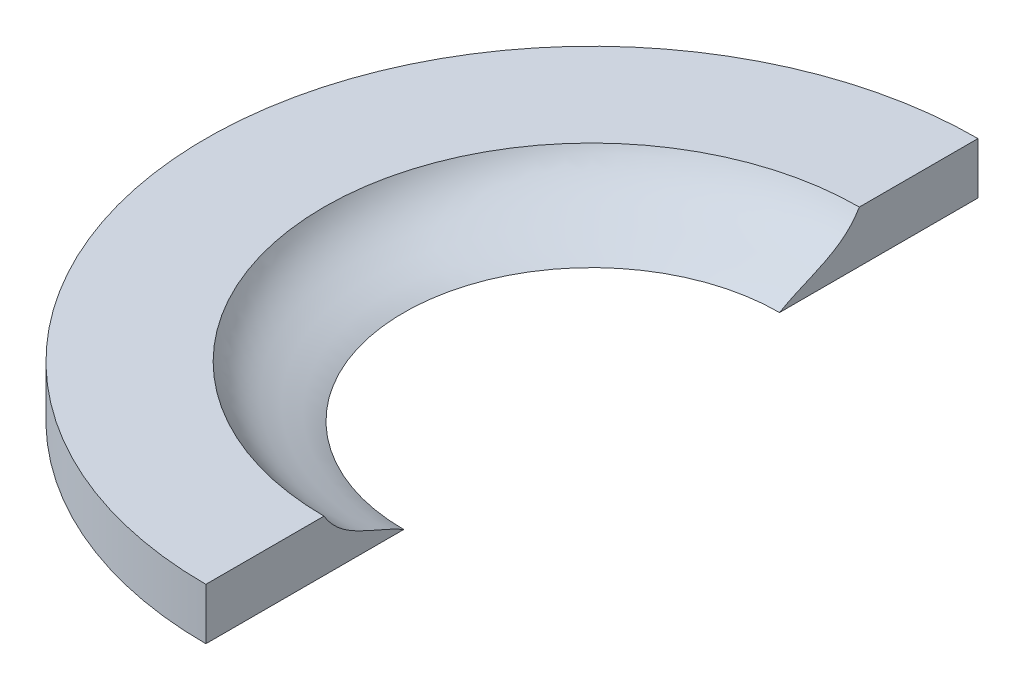
from build123d import *

# Parameters (mm, degrees)
SKETCH1_W           = 127.635
SKETCH1_H           = 127.635
BOSS_EXTRUDE1_DEPTH = 12.7
SKETCH12_R          = 95.4151
BOSS_EXTRUDE2_DEPTH = 12.7
SKETCH5_R           = 46.355
CUT_EXTRUDE1_DEPTH  = 9.525
SKETCH30_R          = 85.09
SKETCH30_R_2        = 79.375
BOSS_EXTRUDE3_DEPTH = 12.7
SKETCH32_R          = 1.35255
CUT_EXTRUDE4_DEPTH  = 15.24
CIRPATTERN2_COUNT   = 12
SKETCH36_R          = 115.31206939
SKETCH36_R_2        = 76.2
CUT_EXTRUDE5_DEPTH  = 35.9250001
SKETCH38_R          = 95.25
SKETCH38_R_2        = 76.2
BOSS_EXTRUDE4_DEPTH = 12.7
SKETCH37_W          = 208.61583397
SKETCH37_H          = 123.882270127
CUT_EXTRUDE6_DEPTH  = 96.25


with BuildPart() as part:
    # Sketch1 → Boss-Extrude1 (new body)
    with BuildSketch(Plane(origin=(0, 0, 0), x_dir=(1, 0, 0), z_dir=(0, 1, 0))):
        with Locations((63.8175, 63.8175)):
            Rectangle(SKETCH1_W, SKETCH1_H)
    extrude(amount=BOSS_EXTRUDE1_DEPTH)

    # Sketch12 → Boss-Extrude2 (add)
    with BuildSketch(Plane.XZ):
        with Locations((63.8175, -63.8175)):
            Circle(SKETCH12_R)
    extrude(amount=-BOSS_EXTRUDE2_DEPTH)

    # Sketch5 → Cut-Extrude1 (cut)
    with BuildSketch(Plane(origin=(0, 12.7, 0), x_dir=(1, 0, 0), z_dir=(0, 1, 0))):
        with Locations((63.8175, 63.8175)):
            Circle(SKETCH5_R)
    extrude(amount=-CUT_EXTRUDE1_DEPTH, mode=Mode.SUBTRACT)

    # Sketch30 → Boss-Extrude3 (add)
    with BuildSketch(Plane.XZ):
        with Locations((63.8175, -63.8175)):
            Circle(SKETCH30_R)
        with Locations((63.8175, -63.8175)):
            Circle(SKETCH30_R_2, mode=Mode.SUBTRACT)
    boss_extrude3 = extrude(amount=BOSS_EXTRUDE3_DEPTH)

    # Mirror1: Boss-Extrude3 across plane
    add(boss_extrude3.mirror(Plane.ZX.offset(4.7625)))

    # Sketch32 → Cut-Extrude4 (cut)
    with BuildSketch(Plane(origin=(0, 0, -148.9075), x_dir=(-1, 0, 0), z_dir=(0, 0, -1))):
        with Locations((-63.8175, -6.35)):
            Circle(SKETCH32_R)
        with Locations((-63.8175, 19.05)):
            Circle(SKETCH32_R)
    cut_extrude4 = extrude(amount=-CUT_EXTRUDE4_DEPTH, mode=Mode.SUBTRACT)

    # CirPattern2: Cut-Extrude4 ×12 about axis
    cirpattern2_axis = Axis((63.8175, -12.7, -63.8175), (0, 1, 0))
    for i in range(1, CIRPATTERN2_COUNT):
        add(cut_extrude4.rotate(cirpattern2_axis, i * 360 / CIRPATTERN2_COUNT), mode=Mode.SUBTRACT)

    # Sketch35 → Cut-Revolve1 (revolve, cut)
    with BuildSketch(Plane.XY.offset(-63.754)):
        with BuildLine():
            add(Edge.make_bspline(
                [(129.8575, 12.7), (125.556720128, 5.300210603), (116.945262531, 3.999403305), (110.1725, 0)],
                knots=[0, 0, 0, 0, 1, 1, 1, 1], degree=3))
            Line((110.1725, 0), (63.8175, 0))
            Line((63.8175, 0), (63.8175, 12.7))
            Line((63.8175, 12.7), (129.8575, 12.7))
        make_face()
    revolve(axis=Axis((63.8175, -10.330163638, -63.754), (0, 1, 0)), mode=Mode.SUBTRACT)

    # Sketch36 → Cut-Extrude5 (cut, through all)
    with BuildSketch(Plane(origin=(0, 22.225, 0), x_dir=(1, 0, 0), z_dir=(0, 1, 0))):
        with Locations((63.8175, 63.8175)):
            Circle(SKETCH36_R)
        with Locations((63.8175, 63.8175)):
            Circle(SKETCH36_R_2, mode=Mode.SUBTRACT)
    extrude(amount=-CUT_EXTRUDE5_DEPTH, mode=Mode.SUBTRACT)

    # Sketch38 → Boss-Extrude4 (add)
    with BuildSketch(Plane(origin=(0, 0, 0), x_dir=(-1, 0, 0), z_dir=(0, -1, 0))):
        with Locations((-63.8175, 63.8175)):
            Circle(SKETCH38_R)
        with Locations((-63.8175, 63.8175)):
            Circle(SKETCH38_R_2, mode=Mode.SUBTRACT)
    extrude(amount=-BOSS_EXTRUDE4_DEPTH)

    # Sketch37 → Cut-Extrude6 (cut, through all)
    with BuildSketch(Plane(origin=(63.8175, 0, 0), x_dir=(0, 0, -1), z_dir=(-1, 0, 0))):
        with Locations((61.023743595, -14.657491218)):
            Rectangle(SKETCH37_W, SKETCH37_H)
    extrude(amount=-CUT_EXTRUDE6_DEPTH, mode=Mode.SUBTRACT)


solid = part.part
